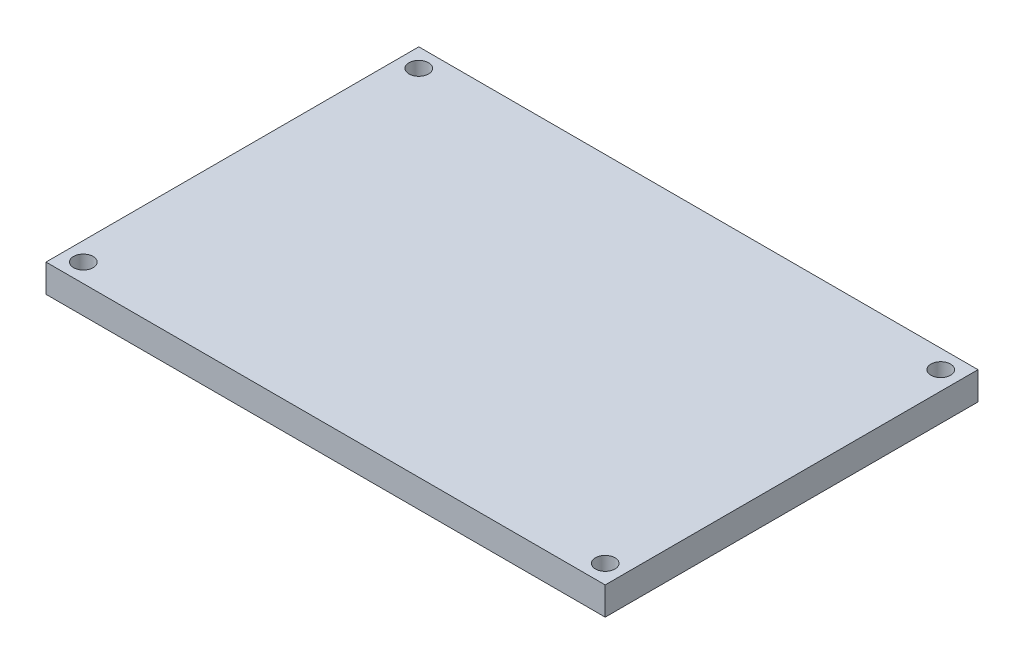
from build123d import *

# Parameters (mm, degrees)
CROQUIS1_W              = 60
CROQUIS1_H              = 40
CROQUIS1_R              = 1.05
SALIENTE_EXTRUIR1_DEPTH = 3


with BuildPart() as part:
    # Croquis1 → Saliente-Extruir1 (new body)
    with BuildSketch(Plane(origin=(0, 0, 0), x_dir=(1, 0, 0), z_dir=(0, 1, 0))):
        Rectangle(CROQUIS1_W, CROQUIS1_H)
        with Locations((-28, 18)):
            Circle(CROQUIS1_R, mode=Mode.SUBTRACT)
        with Locations((-28, -18)):
            Circle(CROQUIS1_R, mode=Mode.SUBTRACT)
        with Locations((28, -18)):
            Circle(CROQUIS1_R, mode=Mode.SUBTRACT)
        with Locations((28, 18)):
            Circle(CROQUIS1_R, mode=Mode.SUBTRACT)
    extrude(amount=SALIENTE_EXTRUIR1_DEPTH)


solid = part.part
